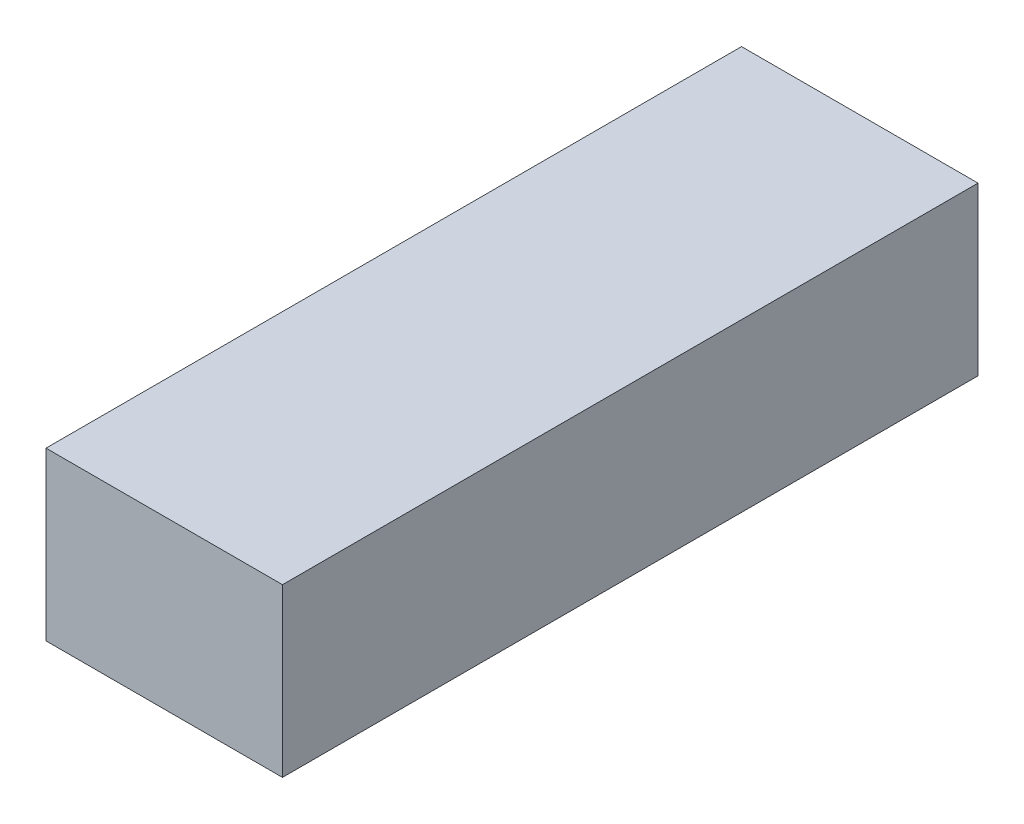
from build123d import *

# Parameters (mm, degrees)
SKETCH1_W           = 11.9
SKETCH1_H           = 35
SKETCH1_W_2         = 7.9
SKETCH1_H_2         = 7.9
BOSS_EXTRUDE1_DEPTH = 2.8
SKETCH2_W           = 11.9
SKETCH2_H           = 35
BOSS_EXTRUDE2_DEPTH = 4
SKETCH3_W           = 11.9
SKETCH3_H           = 35
BOSS_EXTRUDE3_DEPTH = 1.6
CUT_EXTRUDE1_DEPTH  = 7.3
CHAMFER1_SIZE       = 1


with BuildPart() as part:
    # Sketch1 → Boss-Extrude1 (new body)
    with BuildSketch(Plane(origin=(0, 0, 0), x_dir=(1, 0, 0), z_dir=(0, 1, 0))):
        with Locations((0, 9.15)):
            Rectangle(SKETCH1_W, SKETCH1_H)
        Rectangle(SKETCH1_W_2, SKETCH1_H_2, mode=Mode.SUBTRACT)
    extrude(amount=BOSS_EXTRUDE1_DEPTH)

    # Sketch2 → Boss-Extrude2 (add)
    with BuildSketch(Plane(origin=(0, 2.8, 0), x_dir=(1, 0, 0), z_dir=(0, 1, 0))):
        with Locations((0, 9.15)):
            Rectangle(SKETCH2_W, SKETCH2_H)
        Polygon((-3.95, 3.95), (-3.45, 3.95), (-3.45, 24.65), (3.45, 24.65), (3.45, 3.95), (3.95, 3.95), (3.95, -3.95), (-3.95, -3.95), align=None, mode=Mode.SUBTRACT)
        Polygon((3.45, -3.45), (-3.45, -3.45), (-3.45, 3.45), (-3.45, 3.95), (-3.95, 3.95), (-3.95, -3.95), (3.95, -3.95), (3.95, 3.95), (3.45, 3.95), (3.45, 3.45), align=None)
    extrude(amount=BOSS_EXTRUDE2_DEPTH)

    # Sketch3 → Boss-Extrude3 (add)
    with BuildSketch(Plane(origin=(0, 6.8, 0), x_dir=(1, 0, 0), z_dir=(0, 1, 0))):
        with Locations((0, 9.15)):
            Rectangle(SKETCH3_W, SKETCH3_H)
    extrude(amount=BOSS_EXTRUDE3_DEPTH)

    # Sketch4 → Cut-Extrude1 (cut)
    with BuildSketch(Plane(origin=(0, -8.565144899, -3.117457795), x_dir=(-1, 0, 0), z_dir=(0, -0.9396926207859081, -0.34202014332566943))):
        with BuildLine():
            ThreePointArc((4.114090909, 18.618006757), (3.825, 18.917808344), (4.114090909, 19.217609931))
            ThreePointArc((4.114090909, 19.217609931), (2.916815472, 21.834623816), (0.299801587, 23.031899253))
            ThreePointArc((0.299801587, 23.031899253), (0, 22.742808344), (-0.299801587, 23.031899253))
            ThreePointArc((-0.299801587, 23.031899253), (-2.916815472, 21.834623816), (-4.114090909, 19.217609931))
            ThreePointArc((-4.114090909, 19.217609931), (-3.909045459, 19.126047717), (-3.825, 18.917808344))
            ThreePointArc((-3.825, 18.917808344), (-3.909045459, 18.709568971), (-4.114090909, 18.618006757))
            ThreePointArc((-4.114090909, 18.618006757), (-2.916815472, 16.000992872), (-0.299801587, 14.803717435))
            ThreePointArc((-0.299801587, 14.803717435), (0, 15.092808344), (0.299801587, 14.803717435))
            ThreePointArc((0.299801587, 14.803717435), (2.916815472, 16.000992872), (4.114090909, 18.618006757))
        make_face()
    extrude(amount=-CUT_EXTRUDE1_DEPTH, mode=Mode.SUBTRACT)

    # Chamfer1
    chamfer1_edges = [part.edges().sort_by_distance(p)[0] for p in [
        (0, 0, 3.95),
    ]]
    chamfer(chamfer1_edges, length=CHAMFER1_SIZE)


solid = part.part
